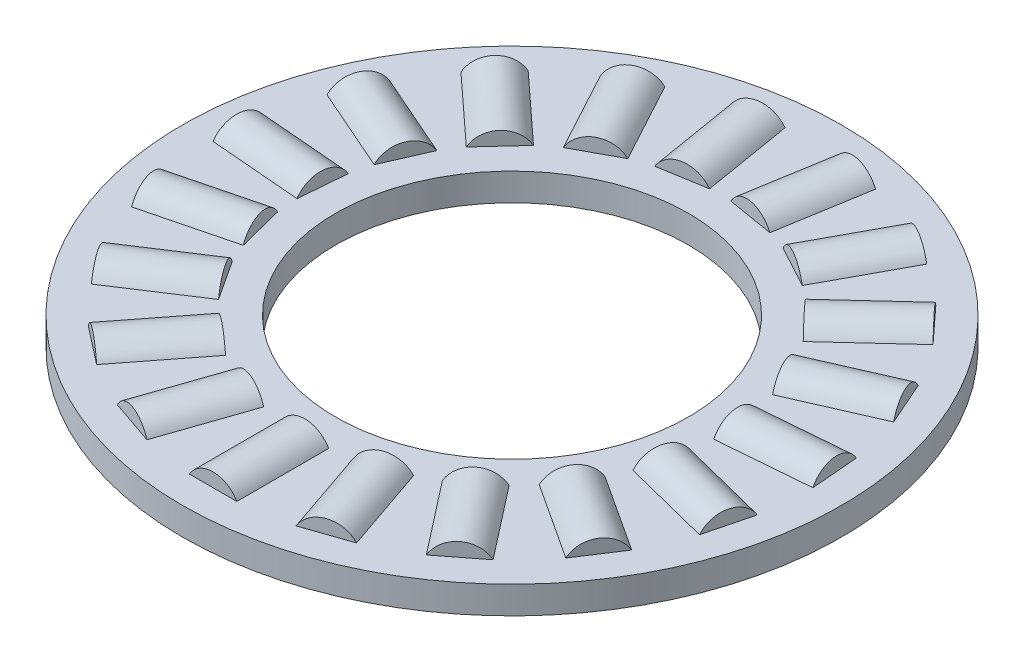
from build123d import *

# Parameters (mm, degrees)
SKETCH5_W         = 5.53085
SKETCH5_H         = 0.9921875
SKETCH3_W         = 3.31851
SKETCH3_H         = 0.9921875
SKETCH2_W         = 3.31851
SKETCH2_H         = 0.9921875
CIRPATTERN1_COUNT = 19
CIRPATTERN1_ANGLE = 341.052631579
CIRPATTERN2_COUNT = 19


with BuildPart() as part:
    # Sketch5 → Revolve3 (revolve)
    with BuildSketch(Plane(origin=(0, 0, 0), x_dir=(0, 0, -1), z_dir=(1, 0, 0))):
        with Locations((-9.140825, 0)):
            Rectangle(SKETCH5_W, SKETCH5_H)
    revolve(axis=Axis((0, -0.9921875, 0), (0, 1, 0)))

    # Sketch3 → Cut-Revolve1 (revolve, cut)
    with BuildSketch(Plane(origin=(0, 0, 0), x_dir=(0, 0, -1), z_dir=(1, 0, 0))):
        with Locations((-9.140825, 0.49609375)):
            Rectangle(SKETCH3_W, SKETCH3_H)
    cut_revolve1 = revolve(axis=Axis((0, 0, 10.80008), (0, 0, -1)), mode=Mode.SUBTRACT)

    # CirPattern2: Cut-Revolve1 ×19 about axis
    cirpattern2_axis = Axis((0, 0.9921875, 0), (0, -1, 0))
    for i in range(1, CIRPATTERN2_COUNT):
        add(cut_revolve1.rotate(cirpattern2_axis, i * 360 / CIRPATTERN2_COUNT), mode=Mode.SUBTRACT)


with BuildPart() as body_2:
    # Sketch2 → Revolve2 (revolve)
    with BuildSketch(Plane(origin=(0, 0, 0), x_dir=(0, 0, -1), z_dir=(1, 0, 0))):
        with Locations((-9.140825, 0.49609375)):
            Rectangle(SKETCH2_W, SKETCH2_H)
    revolve(axis=Axis((0, 0, 10.80008), (0, 0, -1)))


with BuildPart() as cirpattern1_1:
    # CirPattern1: pattern copy
    add(body_2.part.rotate(Axis((0, 0.9921875, 0), (0, -1, 0)), 1 * CIRPATTERN1_ANGLE / (CIRPATTERN1_COUNT - 1)))


with BuildPart() as cirpattern1_2:
    # CirPattern1: pattern copy
    add(body_2.part.rotate(Axis((0, 0.9921875, 0), (0, -1, 0)), 2 * CIRPATTERN1_ANGLE / (CIRPATTERN1_COUNT - 1)))


with BuildPart() as cirpattern1_3:
    # CirPattern1: pattern copy
    add(body_2.part.rotate(Axis((0, 0.9921875, 0), (0, -1, 0)), 3 * CIRPATTERN1_ANGLE / (CIRPATTERN1_COUNT - 1)))


with BuildPart() as cirpattern1_4:
    # CirPattern1: pattern copy
    add(body_2.part.rotate(Axis((0, 0.9921875, 0), (0, -1, 0)), 4 * CIRPATTERN1_ANGLE / (CIRPATTERN1_COUNT - 1)))


with BuildPart() as cirpattern1_5:
    # CirPattern1: pattern copy
    add(body_2.part.rotate(Axis((0, 0.9921875, 0), (0, -1, 0)), 5 * CIRPATTERN1_ANGLE / (CIRPATTERN1_COUNT - 1)))


with BuildPart() as cirpattern1_6:
    # CirPattern1: pattern copy
    add(body_2.part.rotate(Axis((0, 0.9921875, 0), (0, -1, 0)), 6 * CIRPATTERN1_ANGLE / (CIRPATTERN1_COUNT - 1)))


with BuildPart() as cirpattern1_7:
    # CirPattern1: pattern copy
    add(body_2.part.rotate(Axis((0, 0.9921875, 0), (0, -1, 0)), 7 * CIRPATTERN1_ANGLE / (CIRPATTERN1_COUNT - 1)))


with BuildPart() as cirpattern1_8:
    # CirPattern1: pattern copy
    add(body_2.part.rotate(Axis((0, 0.9921875, 0), (0, -1, 0)), 8 * CIRPATTERN1_ANGLE / (CIRPATTERN1_COUNT - 1)))


with BuildPart() as cirpattern1_9:
    # CirPattern1: pattern copy
    add(body_2.part.rotate(Axis((0, 0.9921875, 0), (0, -1, 0)), 9 * CIRPATTERN1_ANGLE / (CIRPATTERN1_COUNT - 1)))


with BuildPart() as cirpattern1_10:
    # CirPattern1: pattern copy
    add(body_2.part.rotate(Axis((0, 0.9921875, 0), (0, -1, 0)), 10 * CIRPATTERN1_ANGLE / (CIRPATTERN1_COUNT - 1)))


with BuildPart() as cirpattern1_11:
    # CirPattern1: pattern copy
    add(body_2.part.rotate(Axis((0, 0.9921875, 0), (0, -1, 0)), 11 * CIRPATTERN1_ANGLE / (CIRPATTERN1_COUNT - 1)))


with BuildPart() as cirpattern1_12:
    # CirPattern1: pattern copy
    add(body_2.part.rotate(Axis((0, 0.9921875, 0), (0, -1, 0)), 12 * CIRPATTERN1_ANGLE / (CIRPATTERN1_COUNT - 1)))


with BuildPart() as cirpattern1_13:
    # CirPattern1: pattern copy
    add(body_2.part.rotate(Axis((0, 0.9921875, 0), (0, -1, 0)), 13 * CIRPATTERN1_ANGLE / (CIRPATTERN1_COUNT - 1)))


with BuildPart() as cirpattern1_14:
    # CirPattern1: pattern copy
    add(body_2.part.rotate(Axis((0, 0.9921875, 0), (0, -1, 0)), 14 * CIRPATTERN1_ANGLE / (CIRPATTERN1_COUNT - 1)))


with BuildPart() as cirpattern1_15:
    # CirPattern1: pattern copy
    add(body_2.part.rotate(Axis((0, 0.9921875, 0), (0, -1, 0)), 15 * CIRPATTERN1_ANGLE / (CIRPATTERN1_COUNT - 1)))


with BuildPart() as cirpattern1_16:
    # CirPattern1: pattern copy
    add(body_2.part.rotate(Axis((0, 0.9921875, 0), (0, -1, 0)), 16 * CIRPATTERN1_ANGLE / (CIRPATTERN1_COUNT - 1)))


with BuildPart() as cirpattern1_17:
    # CirPattern1: pattern copy
    add(body_2.part.rotate(Axis((0, 0.9921875, 0), (0, -1, 0)), 17 * CIRPATTERN1_ANGLE / (CIRPATTERN1_COUNT - 1)))


with BuildPart() as cirpattern1_18:
    # CirPattern1: pattern copy
    add(body_2.part.rotate(Axis((0, 0.9921875, 0), (0, -1, 0)), 18 * CIRPATTERN1_ANGLE / (CIRPATTERN1_COUNT - 1)))


solid = Compound([part.part, body_2.part, cirpattern1_1.part, cirpattern1_2.part, cirpattern1_3.part, cirpattern1_4.part, cirpattern1_5.part, cirpattern1_6.part, cirpattern1_7.part, cirpattern1_8.part, cirpattern1_9.part, cirpattern1_10.part, cirpattern1_11.part, cirpattern1_12.part, cirpattern1_13.part, cirpattern1_14.part, cirpattern1_15.part, cirpattern1_16.part, cirpattern1_17.part, cirpattern1_18.part])
